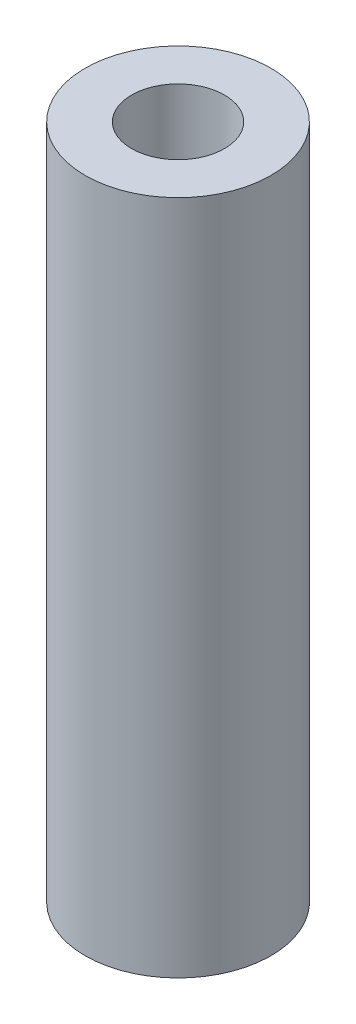
from build123d import *

# Parameters (mm, degrees)
SKETCH1_R           = 11
SKETCH1_R_2         = 5.5
BOSS_EXTRUDE1_DEPTH = 80


with BuildPart() as part:
    # Sketch1 → Boss-Extrude1 (new body)
    with BuildSketch(Plane(origin=(0, 0, 0), x_dir=(1, 0, 0), z_dir=(0, 1, 0))):
        Circle(SKETCH1_R)
        Circle(SKETCH1_R_2, mode=Mode.SUBTRACT)
    extrude(amount=BOSS_EXTRUDE1_DEPTH)


solid = part.part
